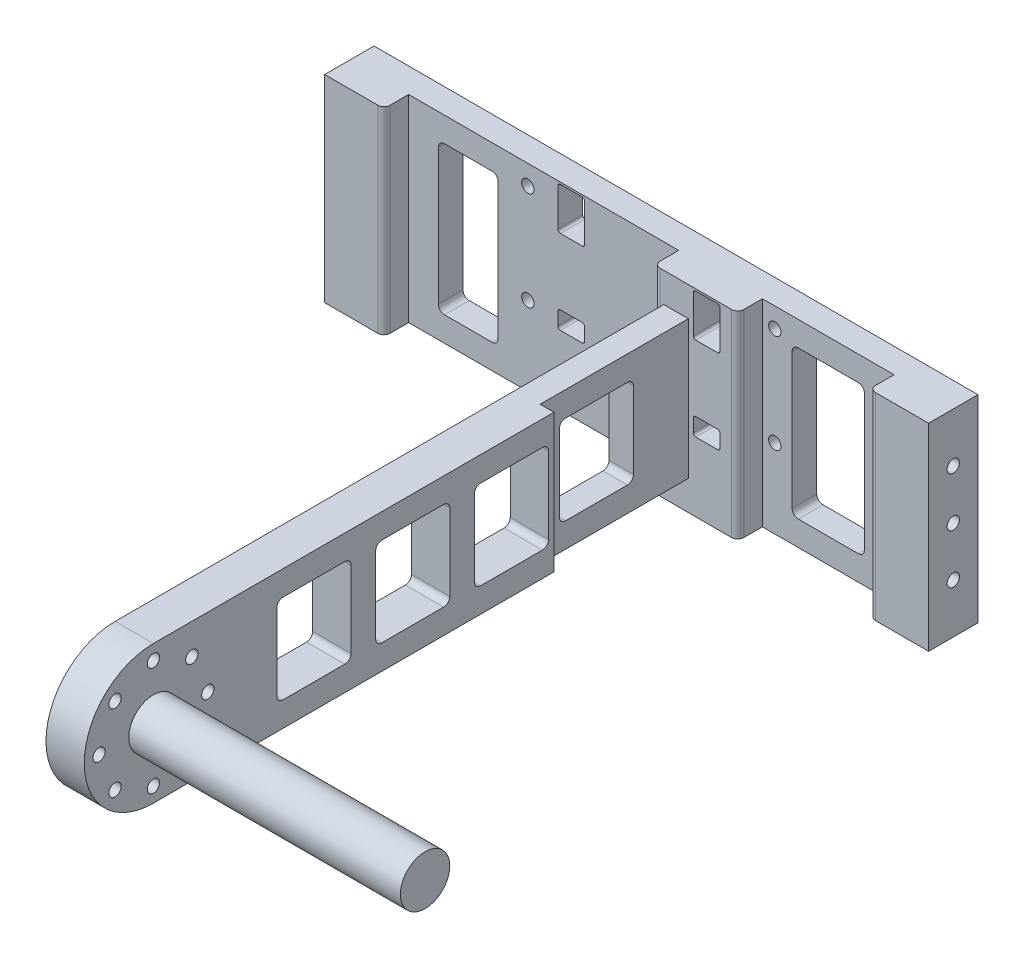
from build123d import *

# Parameters (mm, degrees)
SKETCH1_W           = 122.28
SKETCH1_H           = 40
BOSS_EXTRUDE1_DEPTH = 10
SKETCH2_R           = 3.05
SKETCH2_R_2         = 1.25
CUT_EXTRUDE1_DEPTH  = 10
SKETCH3_R           = 1.25
CUT_EXTRUDE2_DEPTH  = 10
SKETCH4_R           = 5
BOSS_EXTRUDE2_DEPTH = 55
SKETCH5_R           = 14
BOSS_EXTRUDE3_DEPTH = 7.75
SKETCH10_W          = 7.75
SKETCH10_H          = 111.1
BOSS_EXTRUDE4_DEPTH = 28
CUT_EXTRUDE6_REACH  = 158.745
SKETCH8_R           = 1.25
CIRPATTERN2_COUNT   = 8
SKETCH6_R           = 5.05
CUT_EXTRUDE7_DEPTH  = 2
SKETCH11_R          = 2.675
CUT_EXTRUDE8_DEPTH  = 3
SKETCH14_W          = 30
SKETCH14_H          = 28
CUT_EXTRUDE10_DEPTH = 2.8
SKETCH15_R          = 1.25
CUT_EXTRUDE11_DEPTH = 10
SKETCH16_W          = 5.4
SKETCH16_H          = 8.6
SKETCH16_H_2        = 3.6
CUT_EXTRUDE12_DEPTH = 10
FILLET1_R           = 0.5
FILLET2_R           = 0.5
SKETCH17_W          = 54.68
SKETCH17_H          = 40
CUT_EXTRUDE14_DEPTH = 5
SKETCH18_W          = 26.65
SKETCH18_H          = 40
CUT_EXTRUDE15_DEPTH = 5
FILLET4_R           = 1.25
CUT_EXTRUDE17_REACH = 158.745
SKETCH21_W          = 15
SKETCH21_H          = 18
FILLET5_R           = 1.25
CUT_EXTRUDE18_REACH = 194.681
SKETCH22_W          = 14.65
SKETCH22_H          = 30
FILLET6_R           = 1.25
CUT_EXTRUDE19_REACH = 191.208
SKETCH23_W          = 12.14
SKETCH23_H          = 30
FILLET7_R           = 1.25


with BuildPart() as part:
    # Sketch1 → Boss-Extrude1 (new body)
    with BuildSketch(Plane.XY):
        with Locations((61.14, 20)):
            Rectangle(SKETCH1_W, SKETCH1_H)
    extrude(amount=BOSS_EXTRUDE1_DEPTH)

    # Sketch2 → Cut-Extrude1 (cut)
    with BuildSketch(Plane.XY.offset(10)):
        with Locations((61.14, 20)):
            Circle(SKETCH2_R)
        with Locations((76.14, 32.5)):
            Circle(SKETCH2_R_2)
        with Locations((76.14, 15.5)):
            Circle(SKETCH2_R_2)
    cut_extrude1 = extrude(amount=-CUT_EXTRUDE1_DEPTH, mode=Mode.SUBTRACT)

    # Mirror1: Cut-Extrude1 across plane
    add(cut_extrude1.mirror(Plane.ZY.offset(-61.14)), mode=Mode.SUBTRACT)

    # Sketch3 → Cut-Extrude2 (cut)
    with BuildSketch(Plane.ZY):
        with Locations((5, 20)):
            Circle(SKETCH3_R)
        with Locations((5, 30)):
            Circle(SKETCH3_R)
        with Locations((5, 10)):
            Circle(SKETCH3_R)
    cut_extrude2 = extrude(amount=-CUT_EXTRUDE2_DEPTH, mode=Mode.SUBTRACT)

    # Mirror2: Cut-Extrude2 across plane
    add(cut_extrude2.mirror(Plane.ZY.offset(-61.14)), mode=Mode.SUBTRACT)



with BuildPart() as body_2:
    # Sketch4 → Boss-Extrude2 (new body)
    with BuildSketch(Plane(origin=(76.43, 0, 0), x_dir=(0, 0, -1), z_dir=(1, 0, 0))):
        with Locations((-121.1, 20)):
            Circle(SKETCH4_R)
    extrude(amount=BOSS_EXTRUDE2_DEPTH)

    # Sketch5 → Boss-Extrude3 (add)
    with BuildSketch(Plane.ZY.offset(-76.43)):
        with Locations((121.1, 20)):
            Circle(SKETCH5_R)
    extrude(amount=BOSS_EXTRUDE3_DEPTH)


with BuildPart() as part_1:
    add(part.part)

    add(body_2.part)  # Boss-Extrude4 merges body 2
    # Sketch10 → Boss-Extrude4 (add)
    with BuildSketch(Plane(origin=(0, 6, 0), x_dir=(-1, 0, 0), z_dir=(0, -1, 0))):
        with Locations((-72.555, -65.55)):
            Rectangle(SKETCH10_W, SKETCH10_H)
    extrude(amount=-BOSS_EXTRUDE4_DEPTH)

    # Sketch8 → Cut-Extrude6 (cut, up to next)
    with BuildSketch(Plane.ZY.offset(-68.68), mode=Mode.PRIVATE) as cut_extrude6_sk1:
        with Locations((121.1, 9)):
            Circle(SKETCH8_R)
    cut_extrude6_tool1 = extrude(cut_extrude6_sk1.sketch, amount=-CUT_EXTRUDE6_REACH, mode=Mode.PRIVATE) & part_1.part
    cut_extrude6 = cut_extrude6_tool1.solids().sort_by_distance((68.68, 9, 121.1))[0]
    add(cut_extrude6, mode=Mode.SUBTRACT)

    # CirPattern2: Cut-Extrude6 ×8 about axis
    cirpattern2_axis = Axis((68.68, 20, 121.1), (-1, 0, 0))
    for i in range(1, CIRPATTERN2_COUNT):
        add(cut_extrude6.rotate(cirpattern2_axis, i * 360 / CIRPATTERN2_COUNT), mode=Mode.SUBTRACT)

    # Sketch6 → Cut-Extrude7 (cut)
    with BuildSketch(Plane.ZY.offset(-68.68)):
        with Locations((121.1, 20)):
            Circle(SKETCH6_R)
    extrude(amount=-CUT_EXTRUDE7_DEPTH, mode=Mode.SUBTRACT)

    # Sketch11 → Cut-Extrude8 (cut)
    with BuildSketch(Plane.ZY.offset(-70.68)):
        with Locations((121.1, 20)):
            Circle(SKETCH11_R)
    extrude(amount=-CUT_EXTRUDE8_DEPTH, mode=Mode.SUBTRACT)

    # Sketch14 → Cut-Extrude10 (cut)
    with BuildSketch(Plane(origin=(76.43, 0, 0), x_dir=(0, 0, -1), z_dir=(1, 0, 0))):
        with Locations((-25, 20)):
            Rectangle(SKETCH14_W, SKETCH14_H)
    extrude(amount=-CUT_EXTRUDE10_DEPTH, mode=Mode.SUBTRACT)

    # Sketch15 → Cut-Extrude11 (cut)
    with BuildSketch(Plane(origin=(0, 0, 0), x_dir=(-1, 0, 0), z_dir=(0, 0, -1))):
        with Locations((-86.14, 16)):
            Circle(SKETCH15_R)
        with Locations((-86.14, 36)):
            Circle(SKETCH15_R)
    cut_extrude11 = extrude(amount=-CUT_EXTRUDE11_DEPTH, mode=Mode.SUBTRACT)

    # Mirror3: Cut-Extrude11 across plane
    add(cut_extrude11.mirror(Plane.ZY.offset(-61.14)), mode=Mode.SUBTRACT)

    # Sketch16 → Cut-Extrude12 (cut)
    with BuildSketch(Plane(origin=(0, 0, 0), x_dir=(-1, 0, 0), z_dir=(0, 0, -1))):
        with Locations((-77.34, 35.3)):
            Rectangle(SKETCH16_W, SKETCH16_H)
        with Locations((-77.34, 15.8)):
            Rectangle(SKETCH16_W, SKETCH16_H_2)
    cut_extrude12 = extrude(amount=-CUT_EXTRUDE12_DEPTH, mode=Mode.SUBTRACT)

    # Mirror4: Cut-Extrude12 across plane
    add(cut_extrude12.mirror(Plane.ZY.offset(-61.14)), mode=Mode.SUBTRACT)

    # Fillet1
    fillet1_edges = [part_1.edges().sort_by_distance(p)[0] for p in [
        (74.64, 17.6, 5),
        (80.04, 17.6, 5),
        (80.04, 14, 5),
        (74.64, 14, 5),
        (42.24, 17.6, 5),
        (47.64, 17.6, 5),
        (47.64, 14, 5),
        (42.24, 14, 5),
    ]]
    fillet(fillet1_edges, radius=FILLET1_R)

    # Fillet2
    fillet2_edges = [part_1.edges().sort_by_distance(p)[0] for p in [
        (80.04, 31, 5),
        (74.64, 31, 5),
        (80.04, 39.6, 5),
        (74.64, 39.6, 5),
        (47.64, 39.6, 5),
        (42.24, 39.6, 5),
        (47.64, 31, 5),
        (42.24, 31, 5),
    ]]
    fillet(fillet2_edges, radius=FILLET2_R)

    # Sketch17 → Cut-Extrude14 (cut)
    with BuildSketch(Plane.XY.offset(10)):
        with Locations((39.34, 20)):
            Rectangle(SKETCH17_W, SKETCH17_H)
    extrude(amount=-CUT_EXTRUDE14_DEPTH, mode=Mode.SUBTRACT)

    # Sketch18 → Cut-Extrude15 (cut)
    with BuildSketch(Plane.XY.offset(10)):
        with Locations((96.955, 20)):
            Rectangle(SKETCH18_W, SKETCH18_H)
    extrude(amount=-CUT_EXTRUDE15_DEPTH, mode=Mode.SUBTRACT)

    # Fillet4
    fillet4_edges = [part_1.edges().sort_by_distance(p)[0] for p in [
        (12, 20, 10),
        (66.68, 20, 10),
        (83.63, 20, 10),
        (110.28, 20, 10),
    ]]
    fillet(fillet4_edges, radius=FILLET4_R)

    # Sketch21 → Cut-Extrude17 (cut, up to next)
    with BuildSketch(Plane.ZY.offset(-68.68), mode=Mode.PRIVATE) as cut_extrude17_sk1:
        with Locations((88.6, 20)):
            Rectangle(SKETCH21_W, SKETCH21_H)
    cut_extrude17_tool1 = extrude(cut_extrude17_sk1.sketch, amount=-CUT_EXTRUDE17_REACH, mode=Mode.PRIVATE) & part_1.part
    # Sketch21 → Cut-Extrude17 (cut, up to next)
    with BuildSketch(Plane.ZY.offset(-68.68), mode=Mode.PRIVATE) as cut_extrude17_sk2:
        with Locations((68.6, 20)):
            Rectangle(SKETCH21_W, SKETCH21_H)
    cut_extrude17_tool2 = extrude(cut_extrude17_sk2.sketch, amount=-CUT_EXTRUDE17_REACH, mode=Mode.PRIVATE) & part_1.part
    # Sketch21 → Cut-Extrude17 (cut, up to next)
    with BuildSketch(Plane.ZY.offset(-68.68), mode=Mode.PRIVATE) as cut_extrude17_sk3:
        with Locations((48.6, 20)):
            Rectangle(SKETCH21_W, SKETCH21_H)
    cut_extrude17_tool3 = extrude(cut_extrude17_sk3.sketch, amount=-CUT_EXTRUDE17_REACH, mode=Mode.PRIVATE) & part_1.part
    # Sketch21 → Cut-Extrude17 (cut, up to next)
    with BuildSketch(Plane.ZY.offset(-68.68), mode=Mode.PRIVATE) as cut_extrude17_sk4:
        with Locations((28.6, 20)):
            Rectangle(SKETCH21_W, SKETCH21_H)
    cut_extrude17_tool4 = extrude(cut_extrude17_sk4.sketch, amount=-CUT_EXTRUDE17_REACH, mode=Mode.PRIVATE) & part_1.part
    add(cut_extrude17_tool1.solids().sort_by_distance((68.68, 20, 88.6))[0], mode=Mode.SUBTRACT)
    add(cut_extrude17_tool2.solids().sort_by_distance((68.68, 20, 68.6))[0], mode=Mode.SUBTRACT)
    add(cut_extrude17_tool3.solids().sort_by_distance((68.68, 20, 48.6))[0], mode=Mode.SUBTRACT)
    add(cut_extrude17_tool4.solids().sort_by_distance((68.68, 20, 28.6))[0], mode=Mode.SUBTRACT)

    # Fillet5
    fillet5_edges = [part_1.edges().sort_by_distance(p)[0] for p in [
        (71.155, 11, 36.1),
        (71.155, 29, 36.1),
        (71.155, 29, 21.1),
        (71.155, 11, 21.1),
        (72.555, 11, 41.1),
        (72.555, 29, 41.1),
        (72.555, 29, 56.1),
        (72.555, 11, 56.1),
        (72.555, 29, 61.1),
        (72.555, 11, 61.1),
        (72.555, 11, 76.1),
        (72.555, 29, 76.1),
        (72.555, 29, 81.1),
        (72.555, 11, 81.1),
        (72.555, 11, 96.1),
        (72.555, 29, 96.1),
    ]]
    fillet(fillet5_edges, radius=FILLET5_R)

    # Sketch22 → Cut-Extrude18 (cut, up to next)
    with BuildSketch(Plane(origin=(0, 0, 0), x_dir=(-1, 0, 0), z_dir=(0, 0, -1)), mode=Mode.PRIVATE) as cut_extrude18_sk1:
        with Locations((-96.955, 20)):
            Rectangle(SKETCH22_W, SKETCH22_H)
    cut_extrude18_tool1 = extrude(cut_extrude18_sk1.sketch, amount=-CUT_EXTRUDE18_REACH, mode=Mode.PRIVATE) & part_1.part
    add(cut_extrude18_tool1.solids().sort_by_distance((96.955, 20, 0))[0], mode=Mode.SUBTRACT)

    # Fillet6
    fillet6_edges = [part_1.edges().sort_by_distance(p)[0] for p in [
        (104.28, 35, 2.5),
        (89.63, 35, 2.5),
        (89.63, 5, 2.5),
        (104.28, 5, 2.5),
    ]]
    fillet(fillet6_edges, radius=FILLET6_R)

    # Sketch23 → Cut-Extrude19 (cut, up to next)
    with BuildSketch(Plane.XY.offset(5), mode=Mode.PRIVATE) as cut_extrude19_sk1:
        with Locations((24.07, 20)):
            Rectangle(SKETCH23_W, SKETCH23_H)
    cut_extrude19_tool1 = extrude(cut_extrude19_sk1.sketch, amount=-CUT_EXTRUDE19_REACH, mode=Mode.PRIVATE) & part_1.part
    add(cut_extrude19_tool1.solids().sort_by_distance((24.07, 20, 5))[0], mode=Mode.SUBTRACT)

    # Fillet7
    fillet7_edges = [part_1.edges().sort_by_distance(p)[0] for p in [
        (18, 35, 2.5),
        (30.14, 35, 2.5),
        (30.14, 5, 2.5),
        (18, 5, 2.5),
    ]]
    fillet(fillet7_edges, radius=FILLET7_R)


solid = part_1.part
